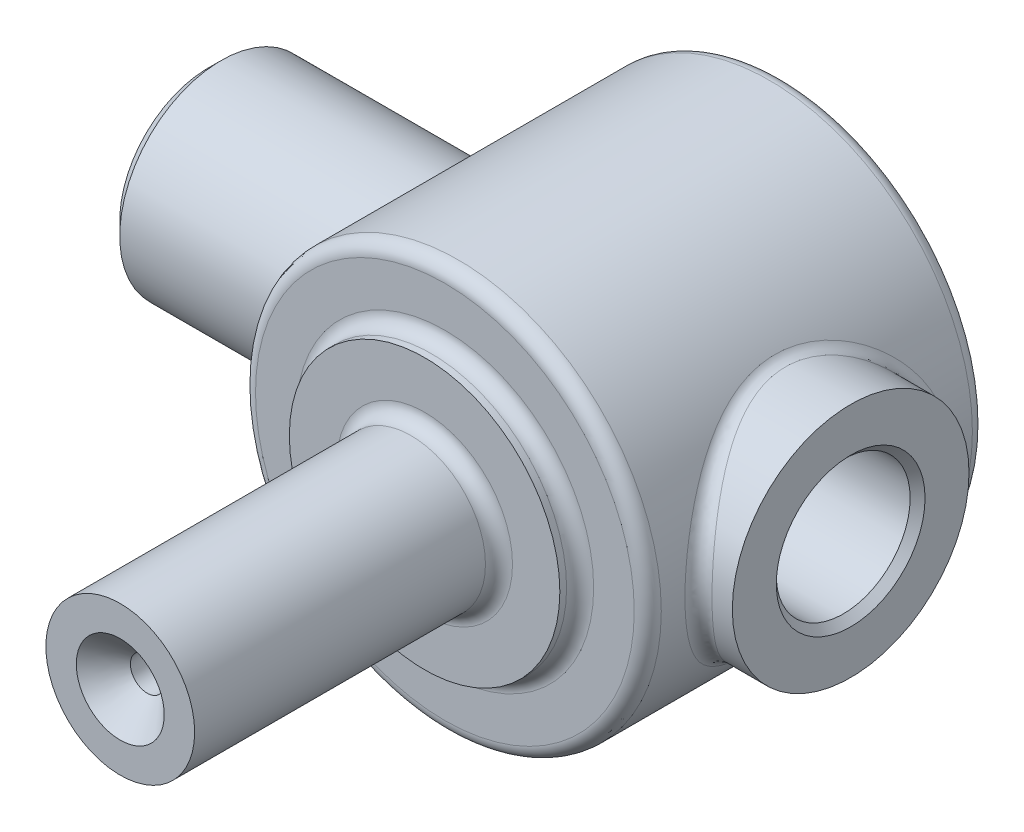
from build123d import *

# Parameters (mm, degrees)
SKETCH_1_R           = 30
EXTRUDE_1_DEPTH      = 50
SKETCH_2_R           = 20
EXTRUDE_2_DEPTH      = 3
SKETCH_3_R           = 11
EXTRUDE_3_DEPTH      = 45
SKETCH_4_R           = 17.5
EXTRUDE_4_DEPTH      = 35
EXTRUDE_4_DEPTH_BACK = 10
SKETCH_8_R           = 15
EXTRUDE_5_DEPTH      = 60
FILLET_1_R           = 2
SKETCH_7_R           = 9.8985
CUT_EXTRUDE_1_DEPTH  = 50
CHAMFER_1_SIZE       = 1.1015
CHAMFER_2_SIZE       = 1.921
CHAMFER_3_SIZE       = 0.828


with BuildPart() as part:
    # Эскиз1 → Бобышка-Вытянуть1 (new body)
    with BuildSketch(Plane.XY):
        Circle(SKETCH_1_R)
    extrude(amount=EXTRUDE_1_DEPTH)

    # Эскиз2 → Бобышка-Вытянуть2 (add)
    with BuildSketch(Plane.XY.offset(50)):
        Circle(SKETCH_2_R)
    extrude(amount=EXTRUDE_2_DEPTH)

    # Эскиз3 → Бобышка-Вытянуть3 (add)
    with BuildSketch(Plane.XY.offset(53)):
        Circle(SKETCH_3_R)
    extrude(amount=EXTRUDE_3_DEPTH)

    # Эскиз4 → Бобышка-Вытянуть4 (add, two sides)
    with BuildSketch(Plane(origin=(0, 0, 0), x_dir=(0, 0, -1), z_dir=(1, 0, 0))) as extrude_4_sk:
        with Locations((-25, 0)):
            Circle(SKETCH_4_R)
    extrude(amount=EXTRUDE_4_DEPTH)
    extrude(extrude_4_sk.sketch, amount=-EXTRUDE_4_DEPTH_BACK)

    # Эскиз8 → Бобышка-Вытянуть5 (add)
    with BuildSketch(Plane(origin=(0, 0, 0), x_dir=(0, 0, -1), z_dir=(1, 0, 0))):
        with Locations((-25, 0)):
            Circle(SKETCH_8_R)
    extrude(amount=-EXTRUDE_5_DEPTH)

    # Эскиз5 → Вырез-Повернуть1 (revolve, cut)
    with BuildSketch(Plane(origin=(0, 0, 0), x_dir=(1, 0, 0), z_dir=(0, 1, 0))):
        Polygon((35, -25), (35, -34.5), (-15, -34.5), (-15, -32.172), (-40, -32.172), (-40, -36), (-60, -36), (-60, -25), align=None)
    revolve(axis=Axis((-60, 0, 25), (1, 0, 0)), mode=Mode.SUBTRACT)

    # Эскиз6 → Вырез-Повернуть2 (revolve, cut)
    with BuildSketch(Plane(origin=(0, 0, 0), x_dir=(1, 0, 0), z_dir=(0, 1, 0))):
        Polygon((6.5, -98), (2.5, -94), (2.5, -30), (0, -30), (0, -98), align=None)
    revolve(axis=Axis((0, 0, 98), (0, 0, -1)), mode=Mode.SUBTRACT)

    # Скругление1
    fillet_1_edges = [part.edges().sort_by_distance(p)[0] for p in [
        (-11, 0, 53),
        (24.366985862, 17.5, 25),
        (-30, 0, 0),
        (-30, 0, 40),
        (-30, 0, 50),
        (-20, 0, 50),
    ]]
    fillet(fillet_1_edges, radius=FILLET_1_R)

    # Эскиз7 → Вырез-Вытянуть1 (cut)
    with BuildSketch(Plane(origin=(35, 0, 0), x_dir=(0, 0, -1), z_dir=(1, 0, 0))):
        with Locations((-25, 0)):
            Circle(SKETCH_7_R)
    extrude(amount=-CUT_EXTRUDE_1_DEPTH, mode=Mode.SUBTRACT)

    # Фаска1
    chamfer_1_edges = [part.edges().sort_by_distance(p)[0] for p in [
        (35, 0, 34.8985),
    ]]
    chamfer(chamfer_1_edges, length=CHAMFER_1_SIZE)

    # Фаска2
    chamfer_2_edges = [part.edges().sort_by_distance(p)[0] for p in [
        (-60, 0, 40),
    ]]
    chamfer(chamfer_2_edges, length=CHAMFER_2_SIZE)

    # Фаска3
    chamfer_3_edges = [part.edges().sort_by_distance(p)[0] for p in [
        (-40, 0, 17.828),
    ]]
    chamfer(chamfer_3_edges, length=CHAMFER_3_SIZE)


solid = part.part
